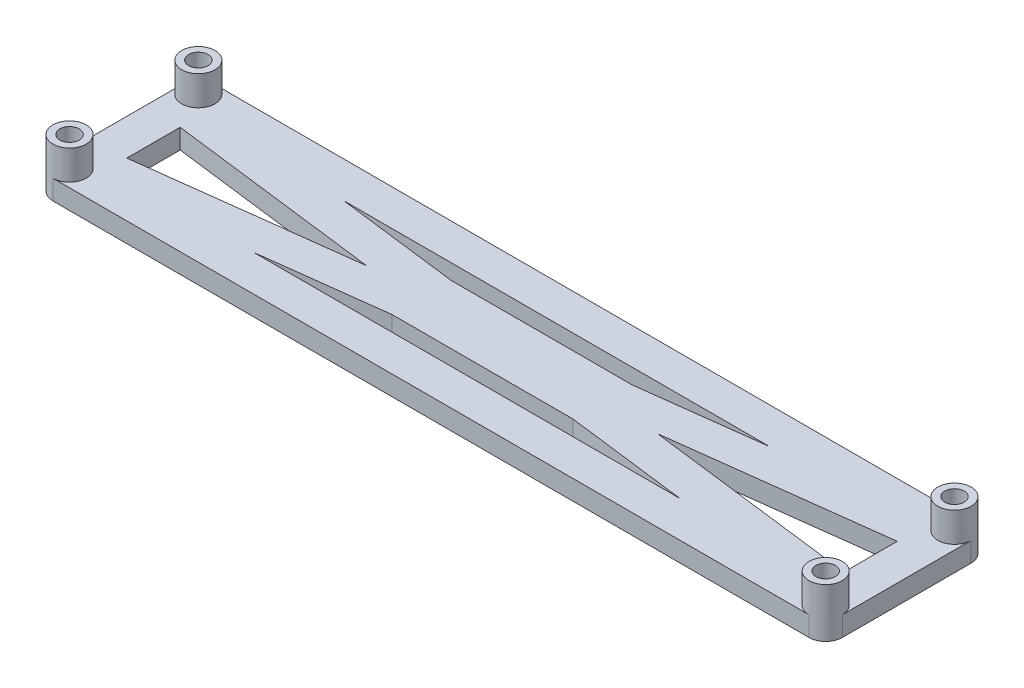
from build123d import *

# Parameters (mm, degrees)
SKETCH2_W               = 80.1
SKETCH2_H               = 16.45
SKETCH2_W_2             = 72.76
SKETCH2_H_2             = 9.11
EXTRUDE_THIN1_DEPTH     = 2
EXTRUDE_THIN2_DEPTH     = 2
SKETCH6_W               = 18.3804486
SKETCH6_H               = 6
BOSS_EXTRUDE2_DEPTH     = 2
SKETCH7_R               = 1.375
BOSS_EXTRUDE3_DEPTH     = 3.8
LPATTERN1_COUNT         = 2
LPATTERN1_PITCH         = 8
FILLET2_R               = 1.69
SKETCH8_R               = 1.69
BOSS_EXTRUDE4_DEPTH     = 3
CUT_EXTRUDE1_START      = 3
SKETCH4_R               = 0.985
CUT_EXTRUDE1_DEPTH      = 4
MIRROR2_COPY_1_SKETCH_R = 1.69
MIRROR2_COPY_1_DEPTH    = 3
MIRROR2_START           = 3
MIRROR2_COPY_2_SKETCH_R = 0.985
MIRROR2_COPY_2_DEPTH    = 4


with BuildPart() as part:
    # Sketch2 → Extrude-Thin1 (new body)
    with BuildSketch(Plane(origin=(0, 0, 0), x_dir=(1, 0, 0), z_dir=(0, 1, 0))):
        Rectangle(SKETCH2_W, SKETCH2_H)
        Rectangle(SKETCH2_W_2, SKETCH2_H_2, mode=Mode.SUBTRACT)
    extrude(amount=EXTRUDE_THIN1_DEPTH)

    # Sketch3 → Extrude-Thin2 (add, through all)
    with BuildSketch(Plane(origin=(0, 2, 0), x_dir=(1, 0, 0), z_dir=(0, 1, 0))):
        Polygon((-36.607973326, 2.734216333), (36.152026674, -6.375783667), (36.607973326, -2.734216333), (-36.152026674, 6.375783667), align=None)
        Polygon((36.152026674, 6.375783667), (-36.607973326, -2.734216333), (-36.152026674, -6.375783667), (36.607973326, 2.734216333), align=None)
    extrude(amount=-EXTRUDE_THIN2_DEPTH)

    # Sketch6 → Boss-Extrude2 (add, through all)
    with BuildSketch(Plane(origin=(0, 2, 0), x_dir=(1, 0, 0), z_dir=(0, 1, 0))):
        Rectangle(SKETCH6_W, SKETCH6_H)
    extrude(amount=-BOSS_EXTRUDE2_DEPTH)

    # Sketch7 → Boss-Extrude3 (add)
    with BuildSketch(Plane(origin=(5.9, 0, 0), x_dir=(0, 0, -1), z_dir=(1, 0, 0))):
        with BuildLine():
            Line((-3, -3.1), (-3, 0))
            Line((-3, 0), (3, 0))
            Line((3, 0), (3, -3.1))
            ThreePointArc((3, -3.1), (0, -6.1), (-3, -3.1))
        make_face()
        with Locations((0, -3.1)):
            Circle(SKETCH7_R, mode=Mode.SUBTRACT)
    boss_extrude3 = extrude(amount=-BOSS_EXTRUDE3_DEPTH)

    # LPattern1: Boss-Extrude3 ×2
    with Locations(*[(-i * LPATTERN1_PITCH, 0, 0) for i in range(1, LPATTERN1_COUNT)]):
        add(boss_extrude3)

    # Fillet2
    fillet2_edges = [part.edges().sort_by_distance(p)[0] for p in [
        (40.05, 1, 8.225),
        (-40.05, 1, 8.225),
        (-40.05, 1, -8.225),
        (40.05, 1, -8.225),
    ]]
    fillet(fillet2_edges, radius=FILLET2_R)

    # Sketch8 → Boss-Extrude4 (add)
    with BuildSketch(Plane(origin=(0, 2, 0), x_dir=(1, 0, 0), z_dir=(0, 1, 0))):
        with Locations((-38.36, 6.535)):
            Circle(SKETCH8_R)
    boss_extrude4 = extrude(amount=BOSS_EXTRUDE4_DEPTH)

    # Sketch4 → Cut-Extrude1 (cut)
    with BuildSketch(Plane(origin=(0, 2, 0), x_dir=(1, 0, 0), z_dir=(0, 1, 0)).offset(CUT_EXTRUDE1_START)):
        with Locations((-38.36, 6.535)):
            Circle(SKETCH4_R)
    cut_extrude1 = extrude(amount=-CUT_EXTRUDE1_DEPTH, mode=Mode.SUBTRACT)

    # Mirror1: Boss-Extrude4, Cut-Extrude1 across plane
    add(boss_extrude4.mirror(Plane.XY))
    add(cut_extrude1.mirror(Plane.XY), mode=Mode.SUBTRACT)

    # Mirror2: Boss-Extrude4, Cut-Extrude1 across plane
    add(boss_extrude4.mirror(Plane(origin=(0, 0, 0), x_dir=(0, 0, 1), z_dir=(1, 0, 0))))
    add(cut_extrude1.mirror(Plane(origin=(0, 0, 0), x_dir=(0, 0, 1), z_dir=(1, 0, 0))), mode=Mode.SUBTRACT)

    # Mirror2 copy 1 sketch → Mirror2 copy 1 (add)
    with BuildSketch(Plane(origin=(0, 2, 0), x_dir=(-1, 0, 0), z_dir=(0, 1, 0))):
        with Locations((-38.36, 6.535)):
            Circle(MIRROR2_COPY_1_SKETCH_R)
    extrude(amount=MIRROR2_COPY_1_DEPTH)

    # Mirror2 copy 2 sketch → Mirror2 copy 2 (cut)
    with BuildSketch(Plane(origin=(0, 2, 0), x_dir=(-1, 0, 0), z_dir=(0, 1, 0)).offset(MIRROR2_START)):
        with Locations((-38.36, 6.535)):
            Circle(MIRROR2_COPY_2_SKETCH_R)
    extrude(amount=-MIRROR2_COPY_2_DEPTH, mode=Mode.SUBTRACT)


solid = part.part
